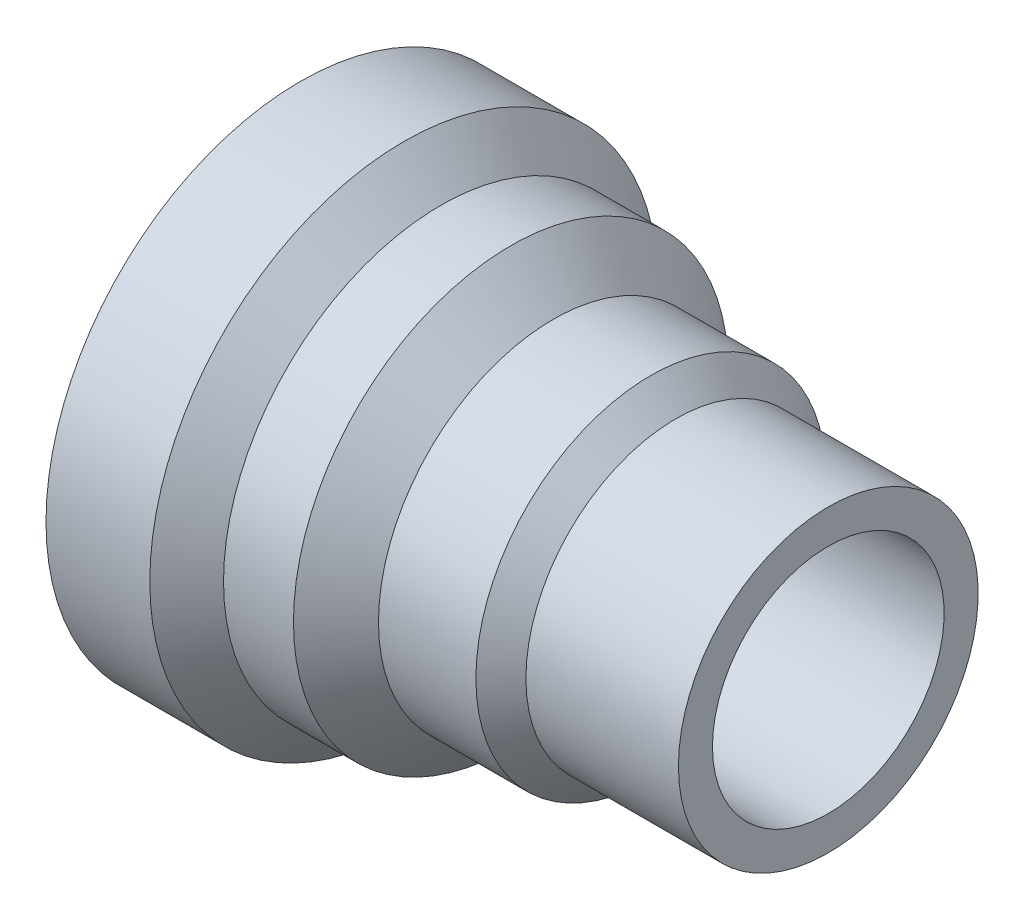
from build123d import *


with BuildPart() as part:
    # Sketch2 → Revolve2 (revolve)
    with BuildSketch(Plane.XY):
        Polygon((-34.669904202, 30.346889679), (-34.669904202, 47.193936562), (-22.034619039, 47.193936562), (-17.548177206, 42.707494729), (-9.033093728, 42.707494729), (-3.859951614, 37.534352615), (7.99707323, 37.534352615), (11.041444474, 34.489981372), (29.605242058, 34.489981372), (29.605242058, 30.346889679), align=None)
    revolve(axis=Axis((-34.669904202, 16.246643918, 0), (1, 0, 0)))


solid = part.part
